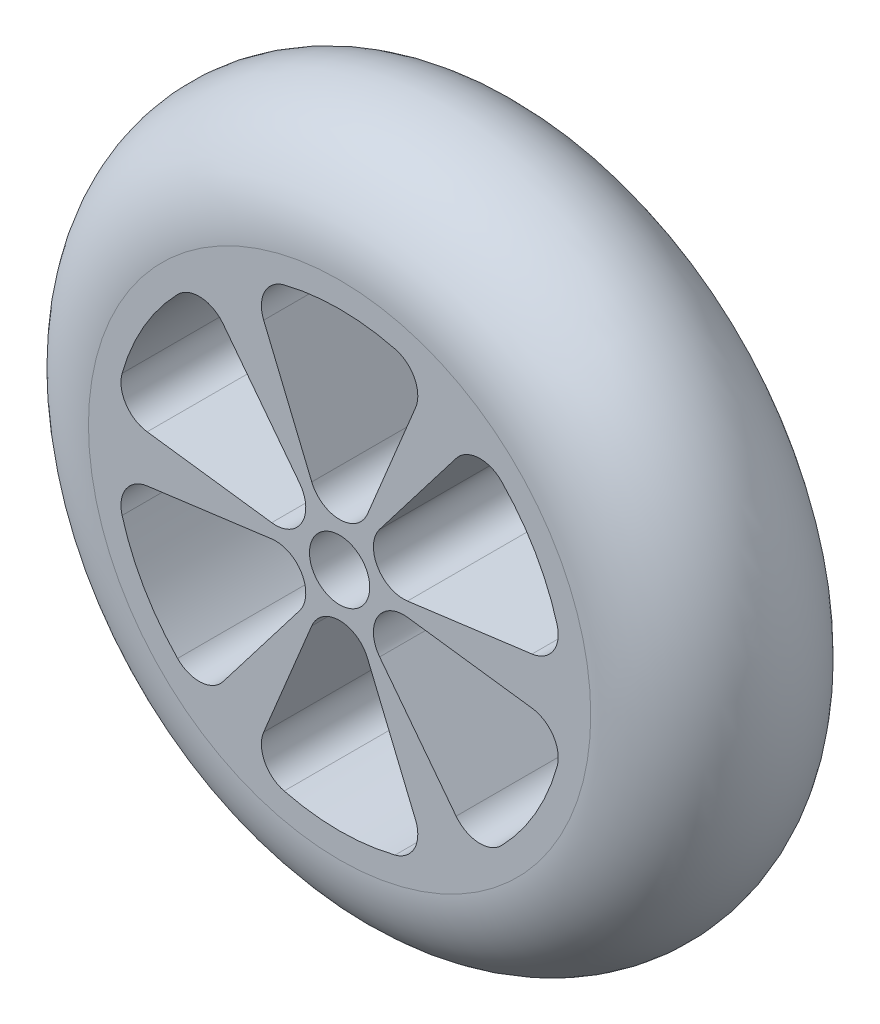
from build123d import *

# Parameters (mm, degrees)
SKETCH5_R           = 50
SKETCH5_R_2         = 6
BOSS_EXTRUDE2_DEPTH = 40
CUT_EXTRUDE1_DEPTH  = 41
CIRPATTERN1_COUNT   = 6


with BuildPart() as part:
    # Sketch5 → Boss-Extrude2 (new body)
    with BuildSketch(Plane.XY):
        Circle(SKETCH5_R)
        Circle(SKETCH5_R_2, mode=Mode.SUBTRACT)
    extrude(amount=BOSS_EXTRUDE2_DEPTH)

    # Sketch7 → Revolve3 (revolve)
    with BuildSketch(Plane(origin=(0, 0, 0), x_dir=(0, 0, -1), z_dir=(1, 0, 0))):
        with BuildLine():
            Line((-40, 50), (0, 50))
            ThreePointArc((0, 50), (-20, 70), (-40, 50))
        make_face()
    revolve(axis=Axis((0, 0, 40), (0, 0, -1)))

    # Sketch8 → Cut-Extrude1 (cut, through all)
    with BuildSketch(Plane.XY.offset(40)):
        with BuildLine():
            Line((5.543277195, 12.406847077), (15.113515228, 35.511445531))
            ThreePointArc((15.113515228, 35.511445531), (14.932932615, 40.498550922), (11.042582345, 43.624091683))
            ThreePointArc((11.042582345, 43.624091683), (0, 45), (-11.042582345, 43.624091683))
            ThreePointArc((-11.042582345, 43.624091683), (-14.932932615, 40.498550922), (-15.113515228, 35.511445531))
            Line((-15.113515228, 35.511445531), (-5.543277195, 12.406847077))
            ThreePointArc((-5.543277195, 12.406847077), (0, 8.702947672), (5.543277195, 12.406847077))
        make_face()
    cut_extrude1 = extrude(amount=-CUT_EXTRUDE1_DEPTH, mode=Mode.SUBTRACT)

    # CirPattern1: Cut-Extrude1 ×6 about axis
    cirpattern1_axis = Axis((0, 0, 0), (0, 0, 1))
    for i in range(1, CIRPATTERN1_COUNT):
        add(cut_extrude1.rotate(cirpattern1_axis, i * 360 / CIRPATTERN1_COUNT), mode=Mode.SUBTRACT)


solid = part.part
